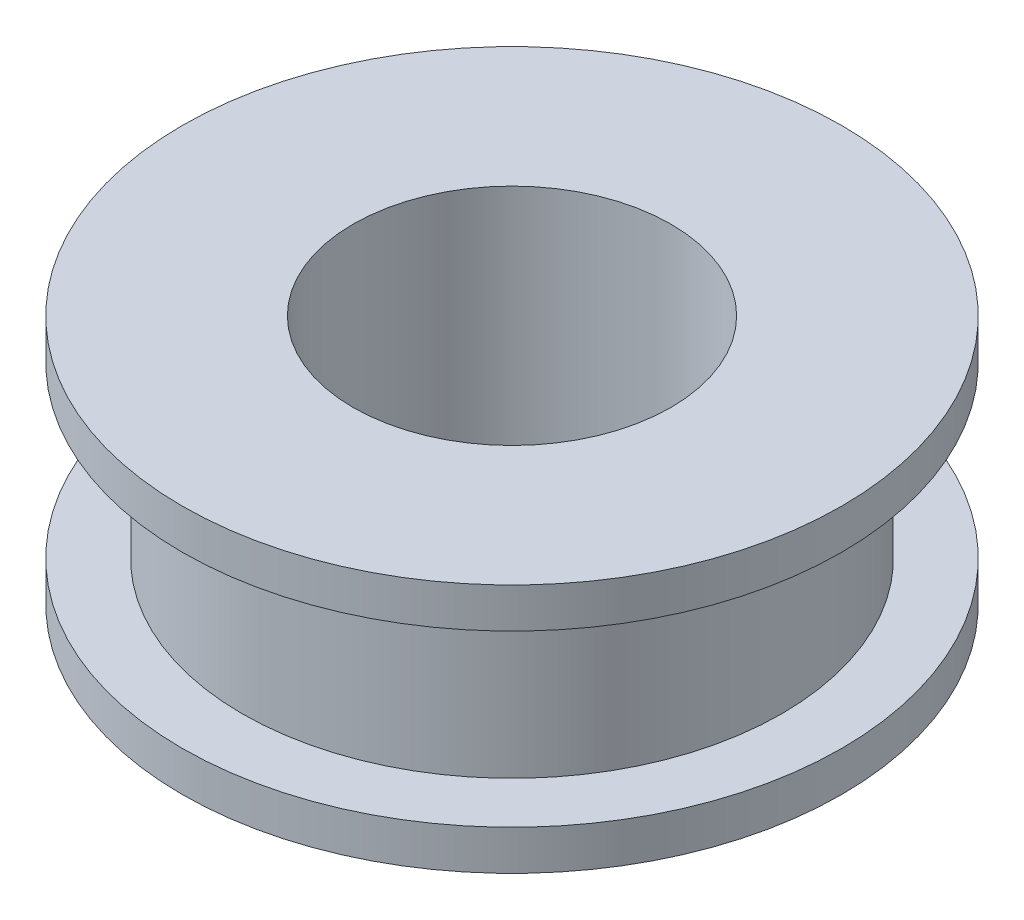
from build123d import *


with BuildPart() as part:
    # 草图1 → 旋转1 (revolve)
    with BuildSketch(Plane.XY):
        Polygon((-7.95, -6.25), (-16.5, -6.25), (-16.5, -4.25), (-13.5, -4.25), (-13.5, 4.25), (-16.5, 4.25), (-16.5, 6.25), (-7.95, 6.25), align=None)
    revolve(axis=Axis((0, 35.139368095, 0), (0, -1, 0)))


solid = part.part
